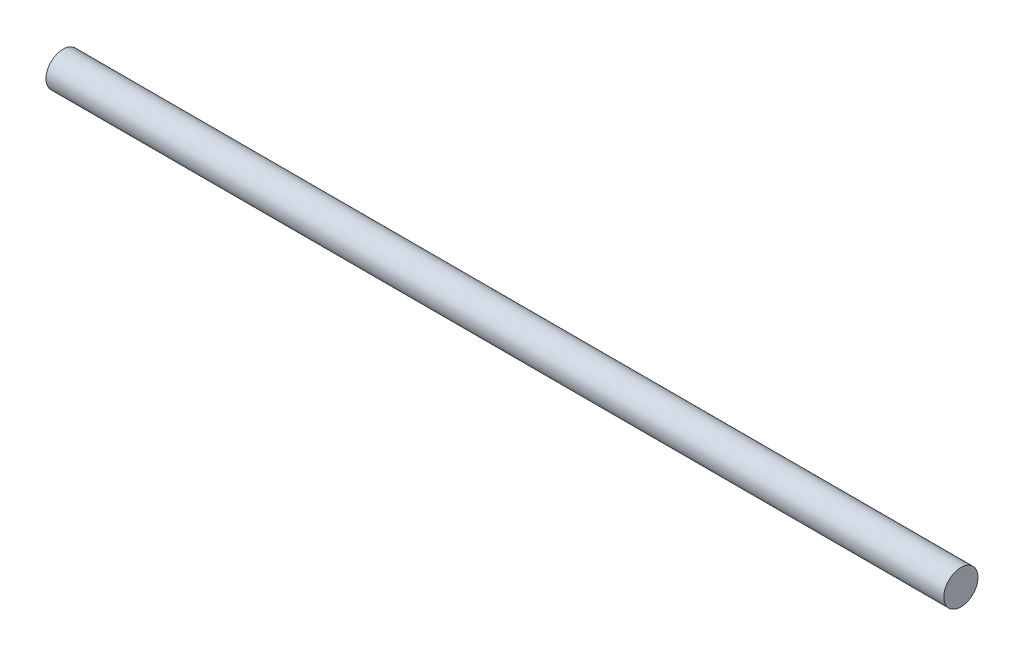
from build123d import *

# Parameters (mm, degrees)
SKETCH1_R           = 4.7625
BOSS_EXTRUDE1_DEPTH = 250


with BuildPart() as part:
    # Sketch1 → Boss-Extrude1 (new body)
    with BuildSketch(Plane(origin=(0, 0, 0), x_dir=(0, 0, -1), z_dir=(1, 0, 0))):
        Circle(SKETCH1_R)
    extrude(amount=BOSS_EXTRUDE1_DEPTH)


solid = part.part
